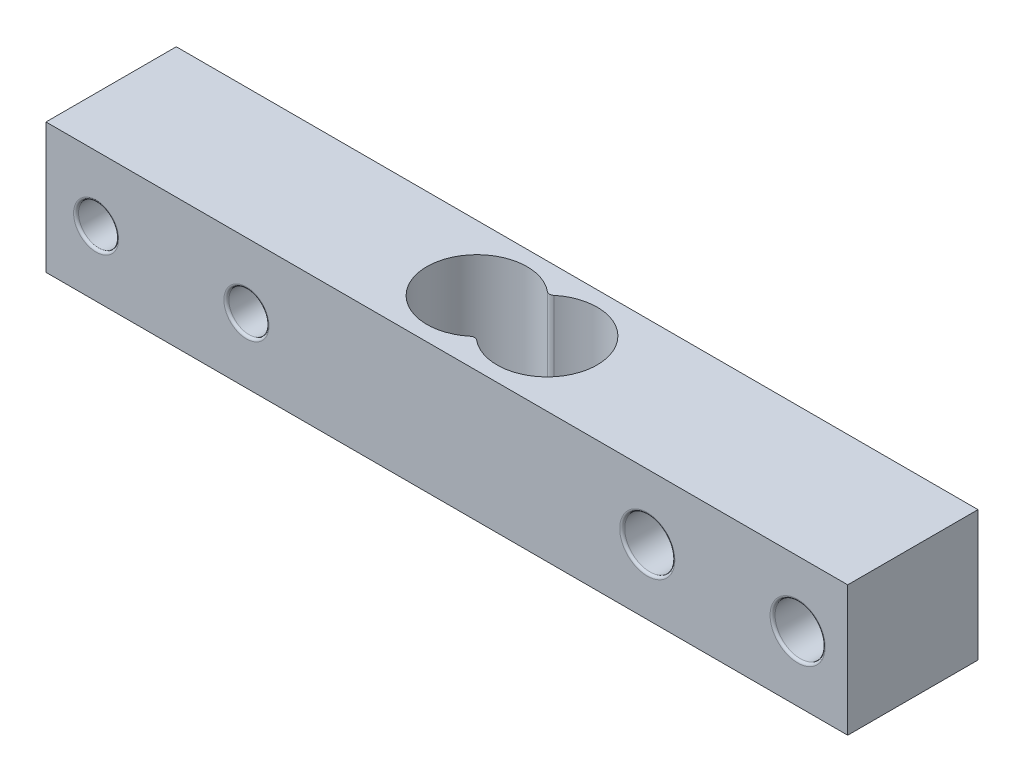
from build123d import *

# Parameters (mm, degrees)
SKETCH1_W                      = 80
SKETCH1_H                      = 13
BOSS_EXTRUDE1_DEPTH            = 13
F_5_0_5_DIAMETER_HOLE1_D       = 5
F_5_0_5_DIAMETER_HOLE1_DEPTH   = 13
F_4_0_4_DIAMETER_HOLE1_D       = 4
F_4_0_4_DIAMETER_HOLE1_DEPTH   = 13
F_4_0_4_DIAMETER_HOLE2_D       = 4
F_4_0_4_DIAMETER_HOLE2_DEPTH   = 13
F_10_0_10_DIAMETER_HOLE1_D     = 10
F_10_0_10_DIAMETER_HOLE1_DEPTH = 13
F_10_0_10_DIAMETER_HOLE2_D     = 10
F_10_0_10_DIAMETER_HOLE2_DEPTH = 13
FILLET1_R                      = 0.25
FILLET2_R                      = 0.5


with BuildPart() as part:
    # Sketch1 → Boss-Extrude1 (new body)
    with BuildSketch(Plane.XZ):
        with Locations((12.020909698, -7.053860091)):
            Rectangle(SKETCH1_W, SKETCH1_H)
    extrude(amount=-BOSS_EXTRUDE1_DEPTH)

    # Ø5.0 (5) Diameter Hole1
    with Locations(Plane.XY.offset(-0.553860091)):
        with Locations((32.020909698, 6.5), (47.020909698, 6.5)):
            Hole(F_5_0_5_DIAMETER_HOLE1_D / 2, depth=F_5_0_5_DIAMETER_HOLE1_DEPTH)

    # Ø4.0 (4) Diameter Hole1
    with Locations(Plane.XY.offset(-0.553860091)):
        with Locations((-7.979090302, 6.5)):
            Hole(F_4_0_4_DIAMETER_HOLE1_D / 2, depth=F_4_0_4_DIAMETER_HOLE1_DEPTH)

    # Ø4.0 (4) Diameter Hole2
    with Locations(Plane(origin=(0, 0, -13.553860091), x_dir=(-1, 0, 0), z_dir=(0, 0, -1))):
        with Locations((22.979090302, 6.5)):
            Hole(F_4_0_4_DIAMETER_HOLE2_D / 2, depth=F_4_0_4_DIAMETER_HOLE2_DEPTH)

    # Ø10.0 (10) Diameter Hole1
    with Locations(Plane(origin=(0, 13, 0), x_dir=(1, 0, 0), z_dir=(0, 1, 0))):
        with Locations((8.520909698, 7.053860091)):
            Hole(F_10_0_10_DIAMETER_HOLE1_D / 2, depth=F_10_0_10_DIAMETER_HOLE1_DEPTH)

    # Ø10.0 (10) Diameter Hole2
    with Locations(Plane(origin=(0, 0, 0), x_dir=(-1, 0, 0), z_dir=(0, -1, 0))):
        with Locations((-15.520909698, 7.053860091)):
            Hole(F_10_0_10_DIAMETER_HOLE2_D / 2, depth=F_10_0_10_DIAMETER_HOLE2_DEPTH)

    # Fillet1
    fillet1_edges = [part.edges().sort_by_distance(p)[0] for p in [
        (49.520909698, 6.5, -0.553860091),
        (49.520909698, 6.5, -13.553860091),
        (34.520909698, 6.5, -0.553860091),
        (34.520909698, 6.5, -13.553860091),
        (-5.979090302, 6.5, -0.553860091),
        (-5.979090302, 6.5, -13.553860091),
        (-24.979090302, 6.5, -13.553860091),
        (-24.979090302, 6.5, -0.553860091),
    ]]
    fillet(fillet1_edges, radius=FILLET1_R)

    # Fillet2
    fillet2_edges = [part.edges().sort_by_distance(p)[0] for p in [
        (12.020909698, 6.5, -3.483145877),
        (12.020909698, 6.5, -10.624574305),
    ]]
    fillet(fillet2_edges, radius=FILLET2_R)


solid = part.part
